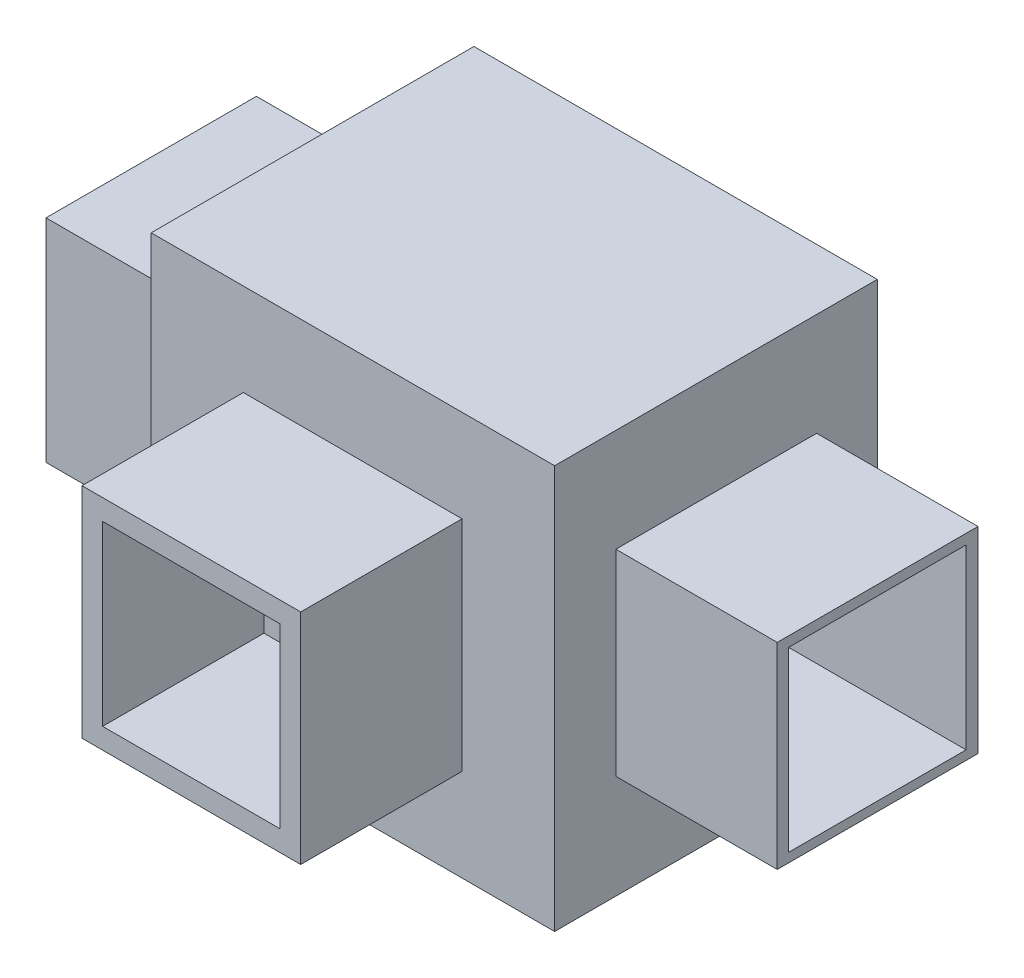
from build123d import *

# Parameters (mm, degrees)
CROQUIS4_W              = 50
CROQUIS4_H              = 50
SALIENTE_EXTRUIR3_DEPTH = 20
CROQUIS5_W              = 27.11028832
CROQUIS5_H              = 27.110288319
CROQUIS5_W_2            = 22
CROQUIS5_H_2            = 22
SALIENTE_EXTRUIR4_DEPTH = 20
CROQUIS6_W              = 50
CROQUIS6_H              = 50
SALIENTE_EXTRUIR5_DEPTH = 20
CROQUIS8_W              = 26.078184682
CROQUIS8_H              = 26.259701678
CROQUIS8_W_2            = 22
CROQUIS8_H_2            = 22
SALIENTE_EXTRUIR6_DEPTH = 20
CROQUIS9_W              = 22
CROQUIS9_H              = 22
CORTAR_EXTRUIR1_DEPTH   = 100
CROQUIS10_W             = 24.8843697
CROQUIS10_H             = 24.378832703
CROQUIS10_W_2           = 22
CROQUIS10_H_2           = 22
SALIENTE_EXTRUIR7_DEPTH = 20


with BuildPart() as part:
    # Croquis4 → Saliente-Extruir3 (new body)
    with BuildSketch(Plane.XY):
        with Locations((-56.246603844, -3.60670653)):
            Rectangle(CROQUIS4_W, CROQUIS4_H)
    extrude(amount=SALIENTE_EXTRUIR3_DEPTH)

    # Croquis5 → Saliente-Extruir4 (add)
    with BuildSketch(Plane.XY.offset(20)):
        with Locations((-56.269779766, -3.594701622)):
            Rectangle(CROQUIS5_W, CROQUIS5_H)
        with Locations((-56.269779766, -3.594701623)):
            Rectangle(CROQUIS5_W_2, CROQUIS5_H_2, mode=Mode.SUBTRACT)
    extrude(amount=SALIENTE_EXTRUIR4_DEPTH)

    # Croquis6 → Saliente-Extruir5 (add)
    with BuildSketch(Plane(origin=(0, 0, 0), x_dir=(-1, 0, 0), z_dir=(0, 0, -1))):
        with Locations((56.246603844, -3.60670653)):
            Rectangle(CROQUIS6_W, CROQUIS6_H)
    extrude(amount=SALIENTE_EXTRUIR5_DEPTH)

    # Croquis8 → Saliente-Extruir6 (add)
    with BuildSketch(Plane.ZY.offset(81.246603844)):
        with Locations((0, -3.60670653)):
            Rectangle(CROQUIS8_W, CROQUIS8_H)
        with Locations((0, -3.60670653)):
            Rectangle(CROQUIS8_W_2, CROQUIS8_H_2, mode=Mode.SUBTRACT)
    extrude(amount=SALIENTE_EXTRUIR6_DEPTH)

    # Croquis9 → Cortar-Extruir1 (cut)
    with BuildSketch(Plane.ZY.offset(81.246603844)):
        with Locations((0, -3.60670653)):
            Rectangle(CROQUIS9_W, CROQUIS9_H)
    extrude(amount=-CORTAR_EXTRUIR1_DEPTH, mode=Mode.SUBTRACT)

    # Croquis10 → Saliente-Extruir7 (add)
    with BuildSketch(Plane(origin=(-31.246603844, 0, 0), x_dir=(0, 0, -1), z_dir=(1, 0, 0))):
        with Locations((0.036410849, -3.556262519)):
            Rectangle(CROQUIS10_W, CROQUIS10_H)
        with Locations((0, -3.60670653)):
            Rectangle(CROQUIS10_W_2, CROQUIS10_H_2, mode=Mode.SUBTRACT)
    extrude(amount=SALIENTE_EXTRUIR7_DEPTH)


solid = part.part
